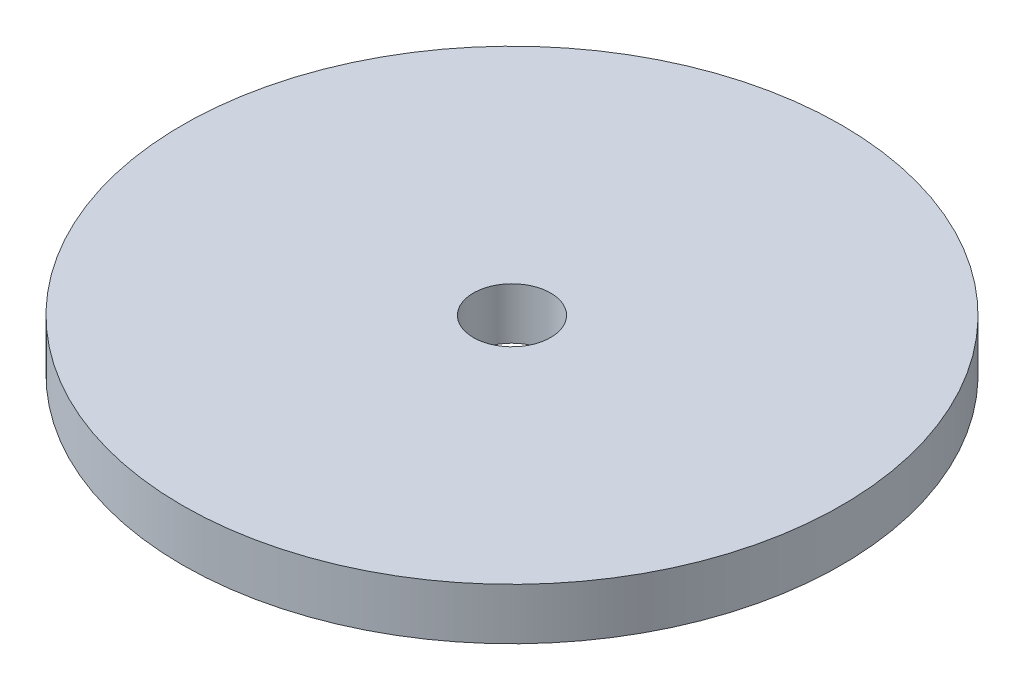
from build123d import *

# Parameters (mm, degrees)
SKETCH1_R           = 40.64
SKETCH1_R_2         = 4.7625
BOSS_EXTRUDE1_DEPTH = 6.35


with BuildPart() as part:
    # Sketch1 → Boss-Extrude1 (new body)
    with BuildSketch(Plane(origin=(0, 0, 0), x_dir=(1, 0, 0), z_dir=(0, 1, 0))):
        Circle(SKETCH1_R)
        Circle(SKETCH1_R_2, mode=Mode.SUBTRACT)
    extrude(amount=BOSS_EXTRUDE1_DEPTH)


solid = part.part
